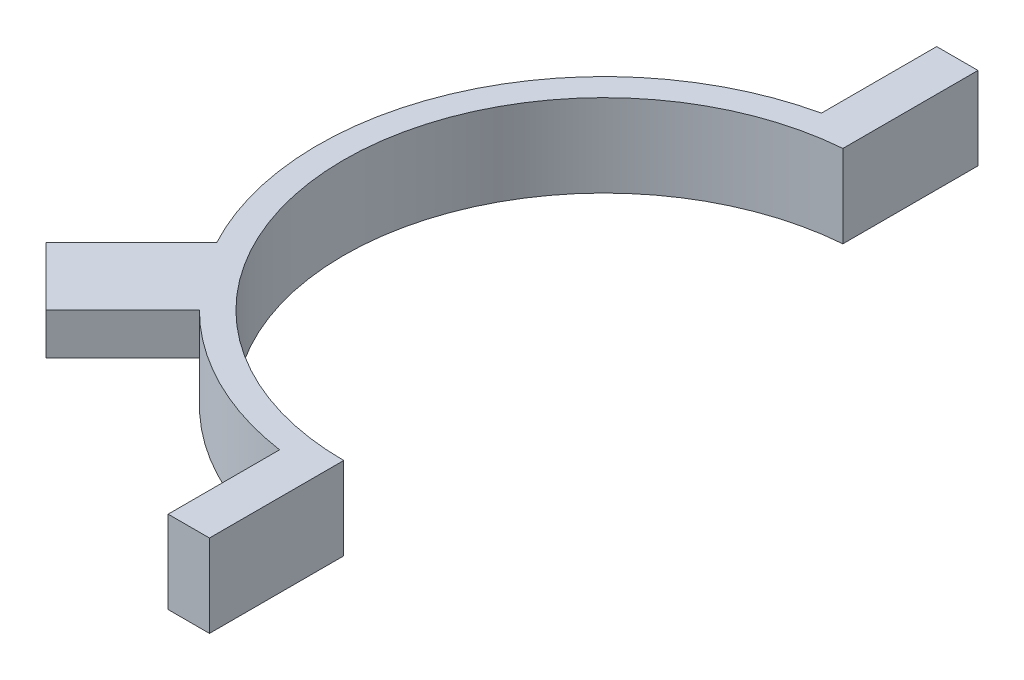
from build123d import *

# Parameters (mm, degrees)
BOSS_EXTRUDE1_DEPTH = 10.16
SKETCH3_W           = 10.16
SKETCH3_H           = 5.08
BOSS_EXTRUDE2_DEPTH = 16.51
SKETCH4_W           = 10.16
SKETCH4_H           = 5.08
BOSS_EXTRUDE3_DEPTH = 16.51
BOSS_EXTRUDE4_DEPTH = 5.08


with BuildPart() as part:
    # Sketch1 → Boss-Extrude1 (new body)
    with BuildSketch(Plane(origin=(0, 0, 0), x_dir=(1, 0, 0), z_dir=(0, 1, 0))):
        with BuildLine():
            Line((0, -32.004), (0, -35.179))
            ThreePointArc((0, -35.179), (-35.156038364, -1.270829481), (-2.54, 35.087183429))
            Line((-2.54, 35.087183429), (-2.54, 31.903047127))
            ThreePointArc((-2.54, 31.903047127), (-31.978751823, -1.271002703), (0, -32.004))
        make_face()
    extrude(amount=BOSS_EXTRUDE1_DEPTH)

    # Sketch3 → Boss-Extrude2 (add)
    with BuildSketch(Plane(origin=(0, 0, 32.004), x_dir=(0, -1, 0), z_dir=(0, 0, -1))):
        with Locations((-5.08, 2.54)):
            Rectangle(SKETCH3_W, SKETCH3_H)
    extrude(amount=-BOSS_EXTRUDE2_DEPTH)

    # Sketch4 → Boss-Extrude3 (add)
    with BuildSketch(Plane(origin=(0, 0, -32.004), x_dir=(0, -1, 0), z_dir=(0, 0, 1))):
        with Locations((-5.08, -5.08)):
            Rectangle(SKETCH4_W, SKETCH4_H)
    extrude(amount=-BOSS_EXTRUDE3_DEPTH)

    # Sketch5 → Boss-Extrude4 (add)
    with BuildSketch(Plane(origin=(0, 10.16, 0), x_dir=(1, 0, 0), z_dir=(0, 1, 0))):
        Polygon((-22.630245425, -22.630245425), (-34.304578382, -34.304578382), (-41.488783279, -27.120373486), (-29.814450322, -15.446040528), align=None)
    extrude(amount=-BOSS_EXTRUDE4_DEPTH)


solid = part.part
